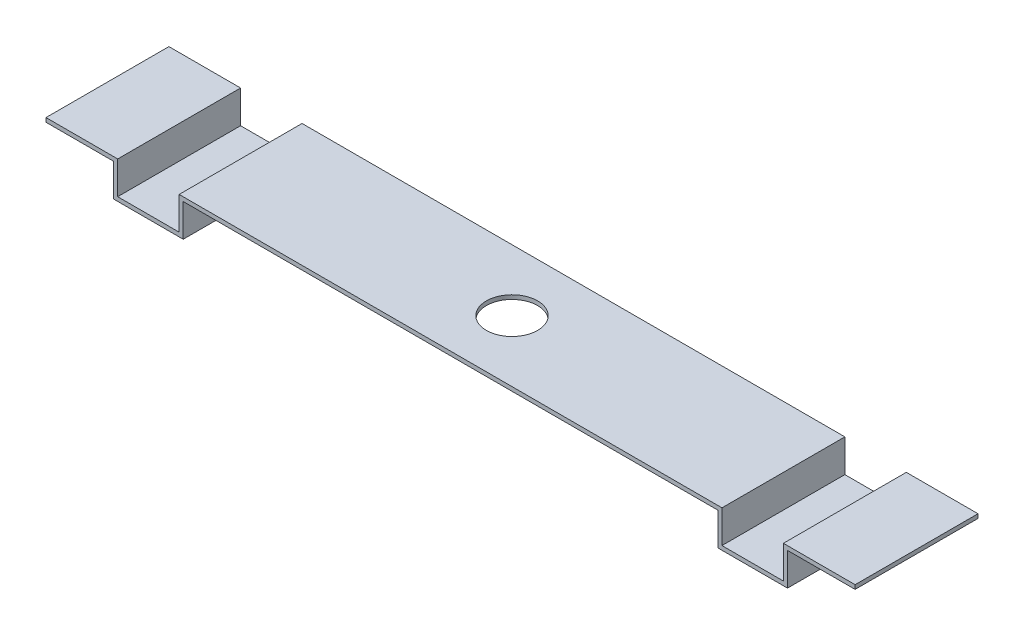
from build123d import *

# Parameters (mm, degrees)
BOSS_EXTRUDE1_DEPTH = 60
SKETCH2_R           = 12.5
CUT_EXTRUDE2_DEPTH  = 60


with BuildPart() as part:
    # Sketch1 → Boss-Extrude1 (new body)
    with BuildSketch(Plane.XY):
        Polygon((305.142857143, 0), (272.142857143, 0), (272.142857143, -15.964285714), (238.142857143, -15.964285714), (238.142857143, 0), (-22.857142857, 0), (-22.857142857, -15.964285714), (-56.857142857, -15.964285714), (-56.857142857, 0), (-89.857142857, 0), (-89.857142857, 2), (-54.857142857, 2), (-54.857142857, -13.964285714), (-24.857142857, -13.964285714), (-24.857142857, 2), (240.142857143, 2), (240.142857143, -13.964285714), (270.142857143, -13.964285714), (270.142857143, 2), (305.142857143, 2), align=None)
    extrude(amount=-BOSS_EXTRUDE1_DEPTH)

    # Sketch2 → Cut-Extrude2 (cut)
    with BuildSketch(Plane(origin=(0, 0, 0), x_dir=(1, 0, 0), z_dir=(0, 1, 0))):
        with Locations((107.642857143, 30)):
            Circle(SKETCH2_R)
    extrude(amount=CUT_EXTRUDE2_DEPTH, mode=Mode.SUBTRACT)


solid = part.part
